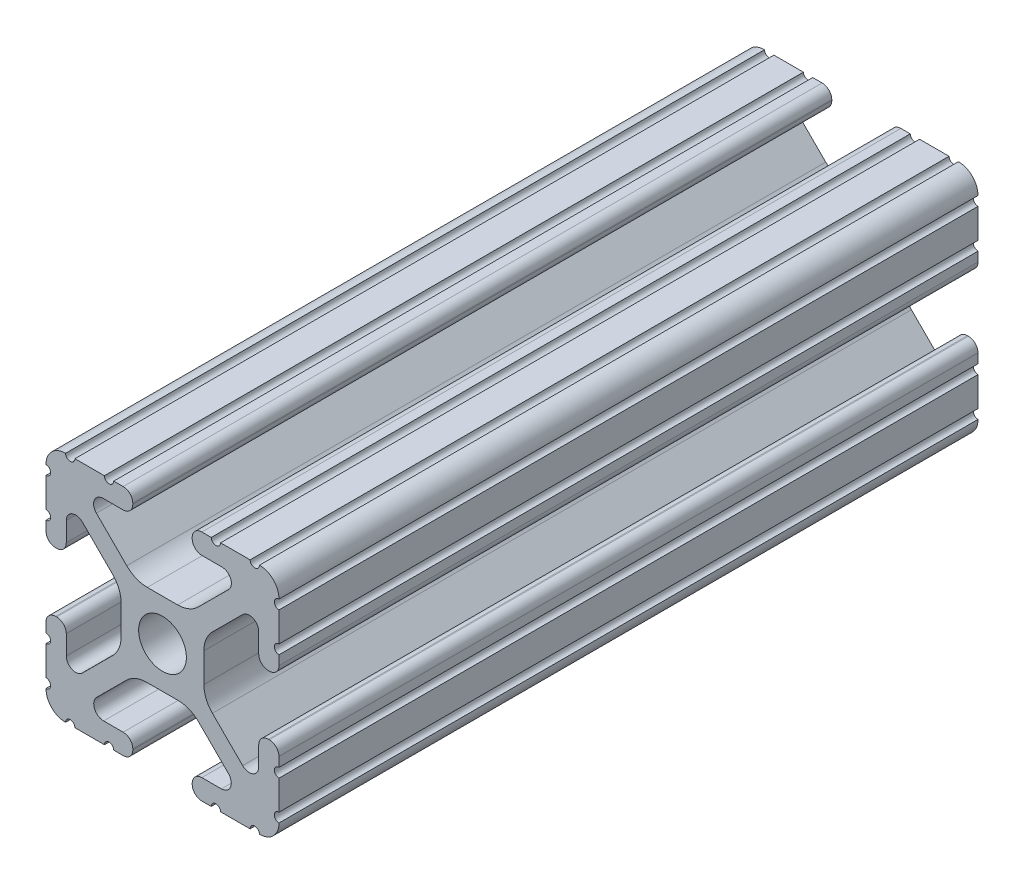
from build123d import *

# Parameters (mm, degrees)
SKETCH1_R           = 2.6035
BOSS_EXTRUDE1_DEPTH = 38.1


with BuildPart() as part:
    # Sketch1 → Boss-Extrude1 (new body, symmetric)
    with BuildSketch(Plane.XY):
        with BuildLine():
            Line((-7.179650497, -8.645192506), (-3.952270251, -5.423690499))
            ThreePointArc((-3.952270251, -5.423690499), (-2.922936451, -4.736929036), (-1.709253557, -4.4958))
            Line((-1.709253557, -4.4958), (1.709253557, -4.4958))
            ThreePointArc((1.709253557, -4.4958), (2.922936451, -4.736929036), (3.952270251, -5.423690499))
            Line((3.952270251, -5.423690499), (7.179650497, -8.645192506))
            ThreePointArc((7.179650497, -8.645192506), (7.41473083, -9.822813117), (6.416408329, -10.4902))
            Line((6.416408329, -10.4902), (4.287512407, -10.4902))
            ThreePointArc((4.287512407, -10.4902), (3.54574862, -10.79744862), (3.2385, -11.539212407))
            Line((3.2385, -11.539212407), (3.2385, -11.650987593))
            ThreePointArc((3.2385, -11.650987593), (3.54574862, -12.39275138), (4.287512407, -12.7))
            Line((4.287512407, -12.7), (5.317126718, -12.7))
            ThreePointArc((5.317126718, -12.7), (5.825126718, -12.192), (6.333126718, -12.7))
            Line((6.333126718, -12.7), (9.550443118, -12.7))
            ThreePointArc((9.550443118, -12.7), (10.058366869, -12.192000006), (10.566443095, -12.699847501))
            ThreePointArc((10.566443095, -12.699847501), (12.082537762, -12.08250727), (12.699846982, -10.566399977))
            ThreePointArc((12.699846982, -10.566399977), (12.192000006, -10.058323491), (12.7, -9.5504))
            Line((12.7, -9.5504), (12.7, -6.3330836))
            ThreePointArc((12.7, -6.3330836), (12.192, -5.8250836), (12.7, -5.3170836))
            Line((12.7, -5.3170836), (12.7, -4.287469289))
            ThreePointArc((12.7, -4.287469289), (12.39275138, -3.545705502), (11.650987593, -3.238456882))
            Line((11.650987593, -3.238456882), (11.539212407, -3.238456882))
            ThreePointArc((11.539212407, -3.238456882), (10.79744862, -3.545705502), (10.4902, -4.287469289))
            Line((10.4902, -4.287469289), (10.4902, -6.402089023))
            ThreePointArc((10.4902, -6.402089023), (9.856505071, -7.351067942), (8.737131347, -7.129408934))
            Line((8.737131347, -7.129408934), (5.441005833, -3.840816462))
            ThreePointArc((5.441005833, -3.840816462), (4.750877967, -2.809883091), (4.5085, -1.593185507))
            Line((4.5085, -1.593185507), (4.5085, 1.593185507))
            ThreePointArc((4.5085, 1.593185507), (4.750877967, 2.809883091), (5.441005833, 3.840816462))
            Line((5.441005833, 3.840816462), (8.737131347, 7.129408934))
            ThreePointArc((8.737131347, 7.129408934), (9.856505071, 7.351067942), (10.4902, 6.402089023))
            Line((10.4902, 6.402089023), (10.4902, 4.287469289))
            ThreePointArc((10.4902, 4.287469289), (10.79744862, 3.545705502), (11.539212407, 3.238456882))
            Line((11.539212407, 3.238456882), (11.650987593, 3.238456882))
            ThreePointArc((11.650987593, 3.238456882), (12.39275138, 3.545705502), (12.7, 4.287469289))
            Line((12.7, 4.287469289), (12.7, 5.3170836))
            ThreePointArc((12.7, 5.3170836), (12.192, 5.8250836), (12.7, 6.3330836))
            Line((12.7, 6.3330836), (12.7, 9.5504))
            ThreePointArc((12.7, 9.5504), (12.192000006, 10.058323491), (12.699846982, 10.566399977))
            ThreePointArc((12.699846982, 10.566399977), (12.082537762, 12.08250727), (10.566443095, 12.699847501))
            ThreePointArc((10.566443095, 12.699847501), (10.058366869, 12.192000006), (9.550443118, 12.7))
            Line((9.550443118, 12.7), (6.333126718, 12.7))
            ThreePointArc((6.333126718, 12.7), (5.825126718, 12.192), (5.317126718, 12.7))
            Line((5.317126718, 12.7), (4.287512407, 12.7))
            ThreePointArc((4.287512407, 12.7), (3.54574862, 12.39275138), (3.2385, 11.650987593))
            Line((3.2385, 11.650987593), (3.2385, 11.539212407))
            ThreePointArc((3.2385, 11.539212407), (3.54574862, 10.79744862), (4.287512407, 10.4902))
            Line((4.287512407, 10.4902), (6.476788598, 10.4902))
            ThreePointArc((6.476788598, 10.4902), (7.432222385, 9.85140422), (7.207036008, 8.724370562))
            Line((7.207036008, 8.724370562), (3.898272566, 5.423169045))
            ThreePointArc((3.898272566, 5.423169045), (2.869120213, 4.736787962), (1.655778399, 4.4958))
            Line((1.655778399, 4.4958), (-1.655778399, 4.4958))
            ThreePointArc((-1.655778399, 4.4958), (-2.869120213, 4.736787962), (-3.898272566, 5.423169045))
            Line((-3.898272566, 5.423169045), (-7.207036008, 8.724370562))
            ThreePointArc((-7.207036008, 8.724370562), (-7.432222385, 9.85140422), (-6.476788598, 10.4902))
            Line((-6.476788598, 10.4902), (-4.287512407, 10.4902))
            ThreePointArc((-4.287512407, 10.4902), (-3.54574862, 10.79744862), (-3.2385, 11.539212407))
            Line((-3.2385, 11.539212407), (-3.2385, 11.650987593))
            ThreePointArc((-3.2385, 11.650987593), (-3.54574862, 12.39275138), (-4.287512407, 12.7))
            Line((-4.287512407, 12.7), (-5.317126718, 12.7))
            ThreePointArc((-5.317126718, 12.7), (-5.825126718, 12.192), (-6.333126718, 12.7))
            Line((-6.333126718, 12.7), (-9.550443118, 12.7))
            ThreePointArc((-9.550443118, 12.7), (-10.058366869, 12.192000006), (-10.566443095, 12.699847501))
            ThreePointArc((-10.566443095, 12.699847501), (-12.082537762, 12.08250727), (-12.699846982, 10.566399977))
            ThreePointArc((-12.699846982, 10.566399977), (-12.192000006, 10.058323491), (-12.7, 9.5504))
            Line((-12.7, 9.5504), (-12.7, 6.3330836))
            ThreePointArc((-12.7, 6.3330836), (-12.192, 5.8250836), (-12.7, 5.3170836))
            Line((-12.7, 5.3170836), (-12.7, 4.287469289))
            ThreePointArc((-12.7, 4.287469289), (-12.39275138, 3.545705502), (-11.650987593, 3.238456882))
            Line((-11.650987593, 3.238456882), (-11.539212407, 3.238456882))
            ThreePointArc((-11.539212407, 3.238456882), (-10.79744862, 3.545705502), (-10.4902, 4.287469289))
            Line((-10.4902, 4.287469289), (-10.4902, 6.402089023))
            ThreePointArc((-10.4902, 6.402089023), (-9.856505071, 7.351067942), (-8.737131347, 7.129408934))
            Line((-8.737131347, 7.129408934), (-5.441005833, 3.840816462))
            ThreePointArc((-5.441005833, 3.840816462), (-4.750877967, 2.809883091), (-4.5085, 1.593185507))
            Line((-4.5085, 1.593185507), (-4.5085, -1.593185507))
            ThreePointArc((-4.5085, -1.593185507), (-4.750877967, -2.809883091), (-5.441005833, -3.840816462))
            Line((-5.441005833, -3.840816462), (-8.737131347, -7.129408934))
            ThreePointArc((-8.737131347, -7.129408934), (-9.856505071, -7.351067942), (-10.4902, -6.402089023))
            Line((-10.4902, -6.402089023), (-10.4902, -4.287469289))
            ThreePointArc((-10.4902, -4.287469289), (-10.79744862, -3.545705502), (-11.539212407, -3.238456882))
            Line((-11.539212407, -3.238456882), (-11.650987593, -3.238456882))
            ThreePointArc((-11.650987593, -3.238456882), (-12.39275138, -3.545705502), (-12.7, -4.287469289))
            Line((-12.7, -4.287469289), (-12.7, -5.3170836))
            ThreePointArc((-12.7, -5.3170836), (-12.192, -5.8250836), (-12.7, -6.3330836))
            Line((-12.7, -6.3330836), (-12.7, -9.5504))
            ThreePointArc((-12.7, -9.5504), (-12.192000006, -10.058323491), (-12.699846982, -10.566399977))
            ThreePointArc((-12.699846982, -10.566399977), (-12.082537762, -12.08250727), (-10.566443095, -12.699847501))
            ThreePointArc((-10.566443095, -12.699847501), (-10.058366869, -12.192000006), (-9.550443118, -12.7))
            Line((-9.550443118, -12.7), (-6.333126718, -12.7))
            ThreePointArc((-6.333126718, -12.7), (-5.825126718, -12.192), (-5.317126718, -12.7))
            Line((-5.317126718, -12.7), (-4.287512407, -12.7))
            ThreePointArc((-4.287512407, -12.7), (-3.54574862, -12.39275138), (-3.2385, -11.650987593))
            Line((-3.2385, -11.650987593), (-3.2385, -11.539212407))
            ThreePointArc((-3.2385, -11.539212407), (-3.54574862, -10.79744862), (-4.287512407, -10.4902))
            Line((-4.287512407, -10.4902), (-6.416408329, -10.4902))
            ThreePointArc((-6.416408329, -10.4902), (-7.41473083, -9.822813117), (-7.179650497, -8.645192506))
        make_face()
        Circle(SKETCH1_R, mode=Mode.SUBTRACT)
    extrude(amount=BOSS_EXTRUDE1_DEPTH, both=True)


solid = part.part
